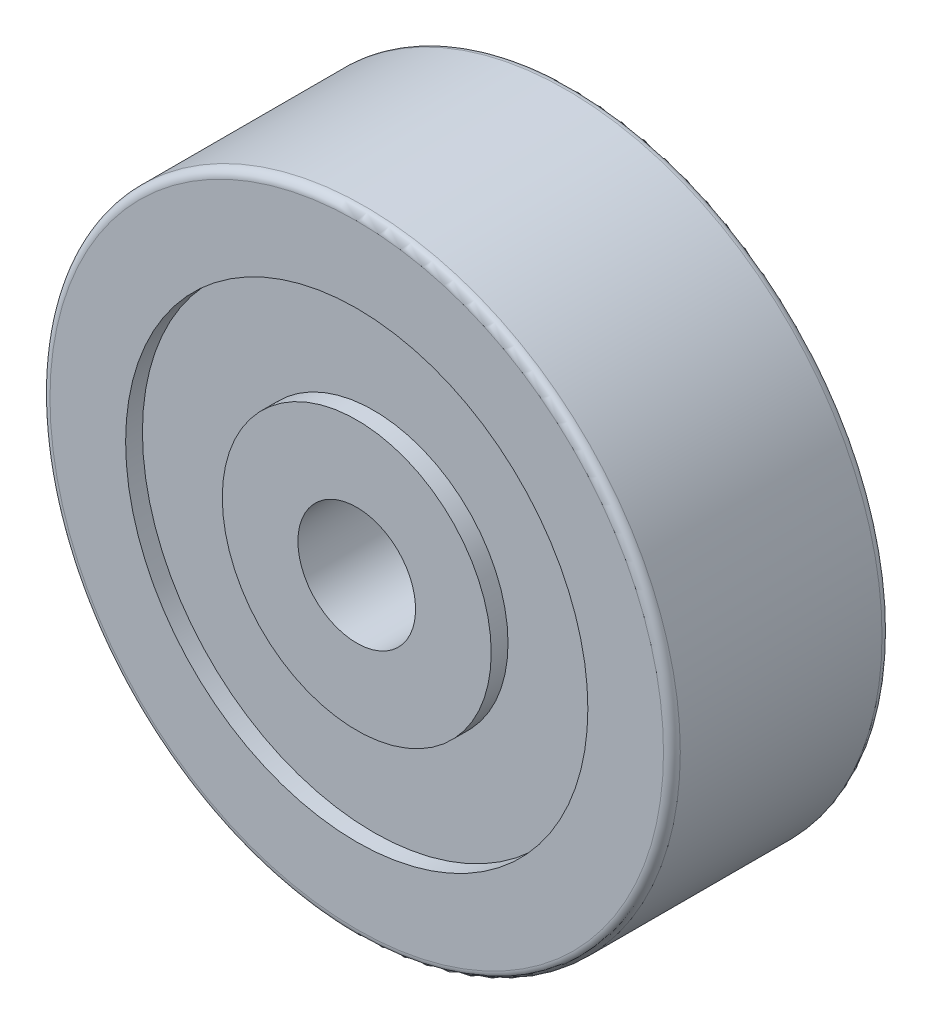
from build123d import *

# Parameters (mm, degrees)
SKETCH1_R           = 37.5
BOSS_EXTRUDE1_DEPTH = 13
SKETCH4_R           = 27.5
CUT_EXTRUDE1_DEPTH  = 2
SKETCH5_R           = 16
BOSS_EXTRUDE2_DEPTH = 2
SKETCH6_R           = 7
CUT_EXTRUDE2_DEPTH  = 27
FILLET1_R           = 1


with BuildPart() as part:
    # Sketch1 → Boss-Extrude1 (new body, symmetric)
    with BuildSketch(Plane.XY):
        Circle(SKETCH1_R)
    extrude(amount=BOSS_EXTRUDE1_DEPTH, both=True)

    # Sketch4 → Cut-Extrude1 (cut)
    with BuildSketch(Plane(origin=(0, 0, -13), x_dir=(-1, 0, 0), z_dir=(0, 0, -1))):
        Circle(SKETCH4_R)
    cut_extrude1 = extrude(amount=-CUT_EXTRUDE1_DEPTH, mode=Mode.SUBTRACT)

    # Mirror1: Cut-Extrude1 across plane
    add(cut_extrude1.mirror(Plane.XY), mode=Mode.SUBTRACT)

    # Sketch5 → Boss-Extrude2 (add)
    with BuildSketch(Plane(origin=(0, 0, -11), x_dir=(-1, 0, 0), z_dir=(0, 0, -1))):
        Circle(SKETCH5_R)
    boss_extrude2 = extrude(amount=BOSS_EXTRUDE2_DEPTH)

    # Mirror2: Boss-Extrude2 across plane
    add(boss_extrude2.mirror(Plane.XY))

    # Sketch6 → Cut-Extrude2 (cut, through all)
    with BuildSketch(Plane(origin=(0, 0, -13), x_dir=(-1, 0, 0), z_dir=(0, 0, -1))):
        Circle(SKETCH6_R)
    extrude(amount=-CUT_EXTRUDE2_DEPTH, mode=Mode.SUBTRACT)

    # Fillet1
    fillet1_edges = [part.edges().sort_by_distance(p)[0] for p in [
        (16, 0, -13),
        (-37.5, 0, 13),
        (-37.5, 0, -13),
        (27.5, 0, -13),
    ]]
    fillet(fillet1_edges, radius=FILLET1_R)


solid = part.part
